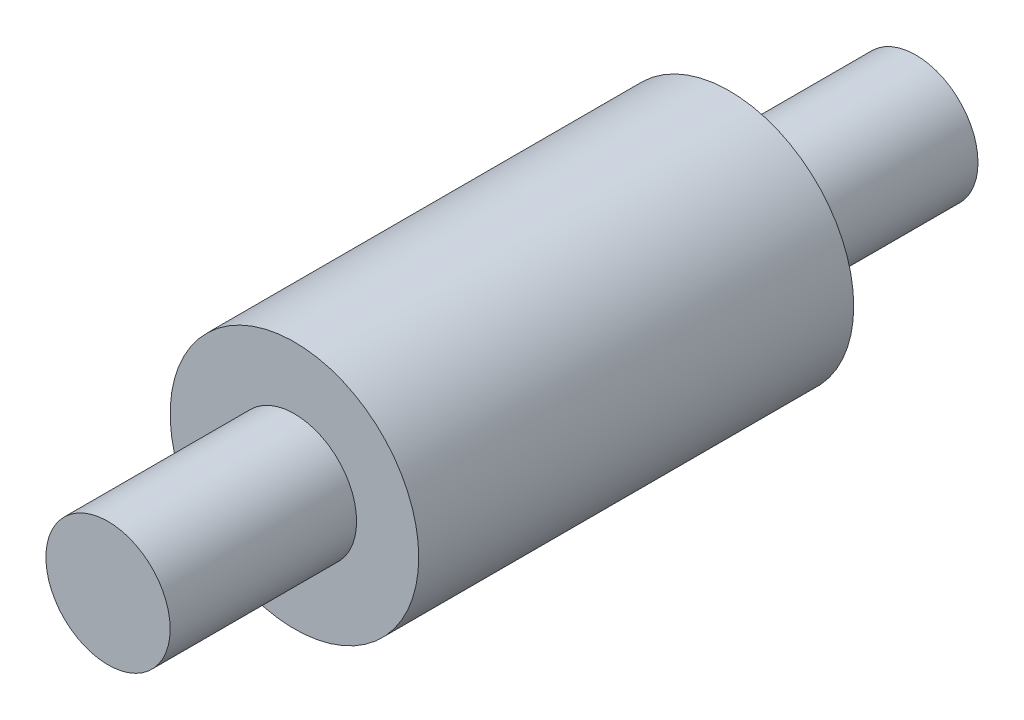
from build123d import *


with BuildPart() as part:
    # Sketch1 → Revolve1 (revolve)
    with BuildSketch(Plane(origin=(0, 0, 0), x_dir=(0, 0, -1), z_dir=(1, 0, 0))):
        Polygon((0, 0), (0, 10), (30, 10), (30, 20), (100, 20), (100, 10), (130, 10), (130, 0), align=None)
    revolve(axis=Axis((0, 0, 43.242398844), (0, 0, -1)))


solid = part.part
